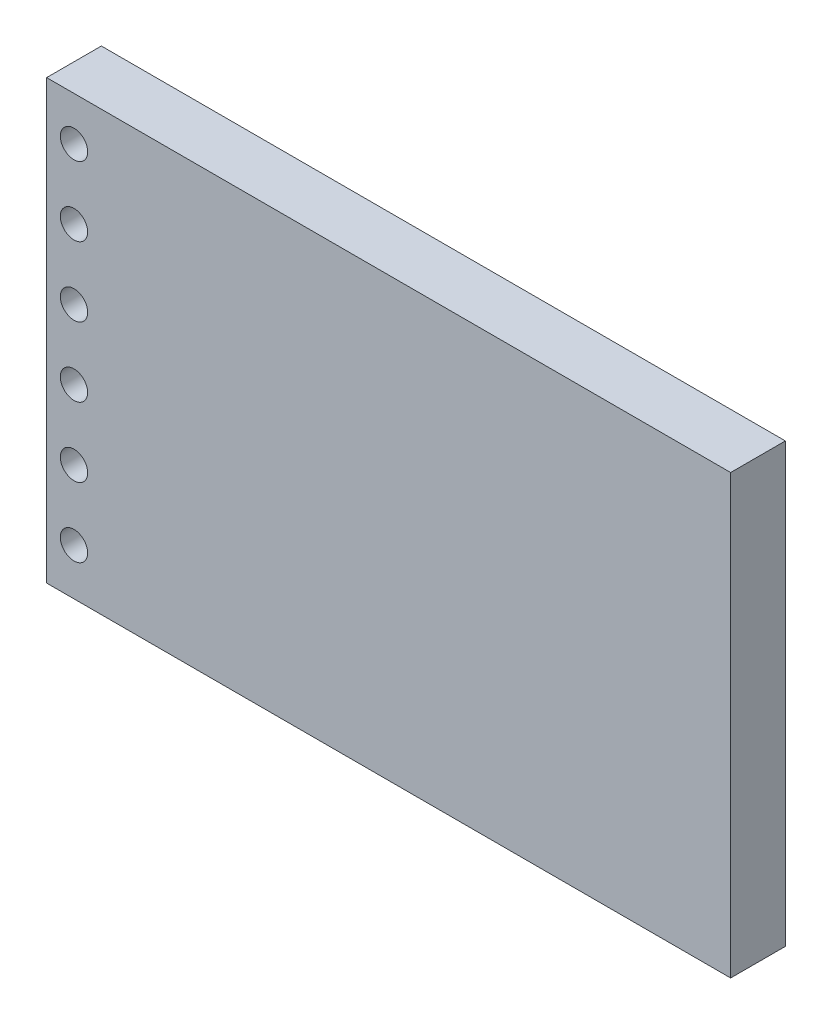
from build123d import *

# Parameters (mm, degrees)
SKETCH_1_W          = 25
SKETCH_1_H          = 16
EXTRUDE_1_DEPTH     = 2
SKETCH_2_R          = 0.5
CUT_EXTRUDE_1_DEPTH = 3
SKETCH_3_W          = 1.998432602
SKETCH_3_H          = 1
EXTRUDE_2_DEPTH     = 0.5
SKETCH_4_W          = 4
SKETCH_4_H          = 2
EXTRUDE_3_DEPTH     = 2
SKETCH_5_W          = 1.76862678
SKETCH_5_H          = 1.058923041
EXTRUDE_4_DEPTH     = 1


with BuildPart() as part:
    # 草图1 → 凸台-拉伸1 (new body)
    with BuildSketch(Plane.XY):
        with Locations((12.5, 8)):
            Rectangle(SKETCH_1_W, SKETCH_1_H)
    extrude(amount=EXTRUDE_1_DEPTH)

    # 草图2 → 切除-拉伸1 (cut, through all)
    with BuildSketch(Plane(origin=(0, 0, 0), x_dir=(-1, 0, 0), z_dir=(0, 0, -1))):
        with Locations((-1, 14.4)):
            Circle(SKETCH_2_R)
        with Locations((-1, 11.86)):
            Circle(SKETCH_2_R)
        with Locations((-1, 9.32)):
            Circle(SKETCH_2_R)
        with Locations((-1, 6.78)):
            Circle(SKETCH_2_R)
        with Locations((-1, 4.24)):
            Circle(SKETCH_2_R)
        with Locations((-1, 1.7)):
            Circle(SKETCH_2_R)
    extrude(amount=-CUT_EXTRUDE_1_DEPTH, mode=Mode.SUBTRACT)

    # 草图3 → 凸台-拉伸2 (add)
    with BuildSketch(Plane(origin=(0, 0, 0), x_dir=(-1, 0, 0), z_dir=(0, 0, -1))):
        with Locations((-22.800563102, 10)):
            Rectangle(SKETCH_3_W, SKETCH_3_H)
        with Locations((-22.800563102, 8)):
            Rectangle(SKETCH_3_W, SKETCH_3_H)
        with Locations((-22.800563102, 6)):
            Rectangle(SKETCH_3_W, SKETCH_3_H)
        with Locations((-22.800563102, 4)):
            Rectangle(SKETCH_3_W, SKETCH_3_H)
    extrude(amount=EXTRUDE_2_DEPTH)

    # 草图4 → 凸台-拉伸3 (add)
    with BuildSketch(Plane(origin=(0, 0, 0), x_dir=(-1, 0, 0), z_dir=(0, 0, -1))):
        with Locations((-20, 1)):
            Rectangle(SKETCH_4_W, SKETCH_4_H)
    extrude(amount=EXTRUDE_3_DEPTH)

    # 草图5 → 凸台-拉伸4 (add)
    with BuildSketch(Plane.XZ):
        with Locations((19.9984492, -0.838988802)):
            Rectangle(SKETCH_5_W, SKETCH_5_H)
    extrude(amount=EXTRUDE_4_DEPTH)


solid = part.part
